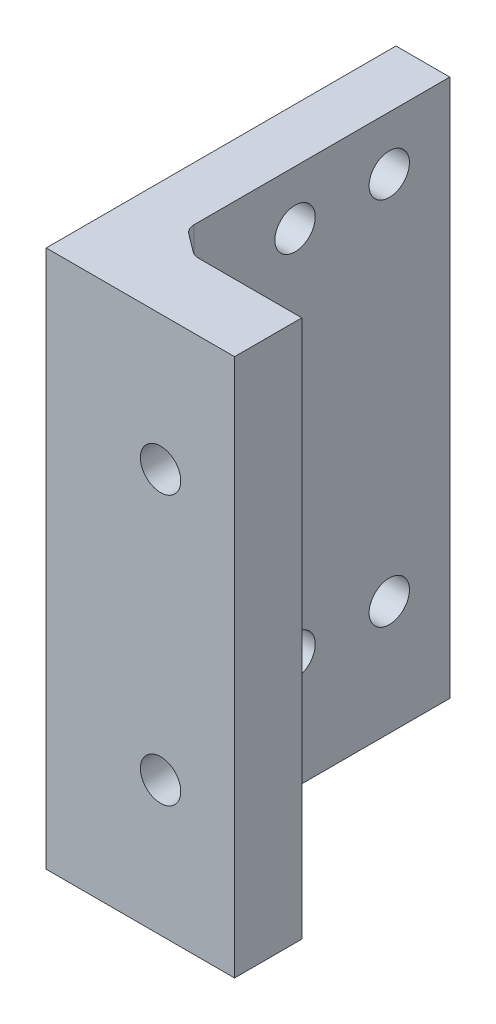
from build123d import *

# Parameters (mm, degrees)
SKETCH1_W                = 4
SKETCH1_H                = 40
BOSS_EXTRUDE2_DEPTH      = 20
BOSS_EXTRUDE2_DEPTH_BACK = 4
SKETCH3_R                = 1.5
CUT_EXTRUDE1_DEPTH       = 29.565713714
SKETCH4_W                = 3
SKETCH4_H                = 40
BOSS_EXTRUDE3_DEPTH      = 10
SKETCH5_R                = 1.5
CUT_EXTRUDE2_DEPTH       = 39.288379438
SKETCH8_W                = 14
SKETCH8_H                = 40
SKETCH8_R                = 1.5
BOSS_EXTRUDE4_DEPTH      = 2
BOSS_EXTRUDE5_DEPTH      = 40
FILLET3_R                = 1


with BuildPart() as part:
    # Sketch1 → Boss-Extrude2 (new, two sides)
    with BuildSketch(Plane.XY) as boss_extrude2_sk:
        with Locations((13, 0)):
            Rectangle(SKETCH1_W, SKETCH1_H)
    extrude(amount=BOSS_EXTRUDE2_DEPTH)
    extrude(boss_extrude2_sk.sketch, amount=-BOSS_EXTRUDE2_DEPTH_BACK)

    # Sketch3 → Cut-Extrude1 (cut, through all)
    with BuildSketch(Plane(origin=(15, 0, 0), x_dir=(0, 0, -1), z_dir=(1, 0, 0))):
        with Locations((-0.5, -11.5)):
            Circle(SKETCH3_R)
        with Locations((-7.5, -11.5)):
            Circle(SKETCH3_R)
        with Locations((-0.5, 16)):
            Circle(SKETCH3_R)
        with Locations((-7.5, 16)):
            Circle(SKETCH3_R)
    extrude(amount=-CUT_EXTRUDE1_DEPTH, mode=Mode.SUBTRACT)

    # Sketch4 → Boss-Extrude3 (add)
    with BuildSketch(Plane(origin=(15, 0, 0), x_dir=(0, 0, -1), z_dir=(1, 0, 0))):
        with Locations((-18.5, 0)):
            Rectangle(SKETCH4_W, SKETCH4_H)
    extrude(amount=BOSS_EXTRUDE3_DEPTH)

    # Sketch5 → Cut-Extrude2 (cut, through all)
    with BuildSketch(Plane(origin=(0, 0, 17), x_dir=(-1, 0, 0), z_dir=(0, 0, -1))):
        with Locations(Location((-19.5, -10, 0), (0, 0, 90))):
            Circle(SKETCH5_R)
        with Locations(Location((-19.5, 10, 0), (0, 0, 90))):
            Circle(SKETCH5_R)
    extrude(amount=-CUT_EXTRUDE2_DEPTH, mode=Mode.SUBTRACT)

    # Sketch8 → Boss-Extrude4 (add)
    with BuildSketch(Plane.XY.offset(20)):
        with Locations((18, 0)):
            Rectangle(SKETCH8_W, SKETCH8_H)
        with Locations(Location((19.5, 10, 0), (0, 0, 90))):
            Circle(SKETCH8_R, mode=Mode.SUBTRACT)
        with Locations(Location((19.5, -10, 0), (0, 0, 90))):
            Circle(SKETCH8_R, mode=Mode.SUBTRACT)
    extrude(amount=BOSS_EXTRUDE4_DEPTH)

    # Sketch9 → Boss-Extrude5 (add)
    with BuildSketch(Plane.XZ.offset(20)):
        Polygon((17, 17), (15, 17), (15, 15.5), align=None)
    extrude(amount=-BOSS_EXTRUDE5_DEPTH)

    # Fillet3
    fillet3_edges = [part.edges().sort_by_distance(p)[0] for p in [
        (15, 0, 15.5),
        (17, 0, 17),
    ]]
    fillet(fillet3_edges, radius=FILLET3_R)


solid = part.part
